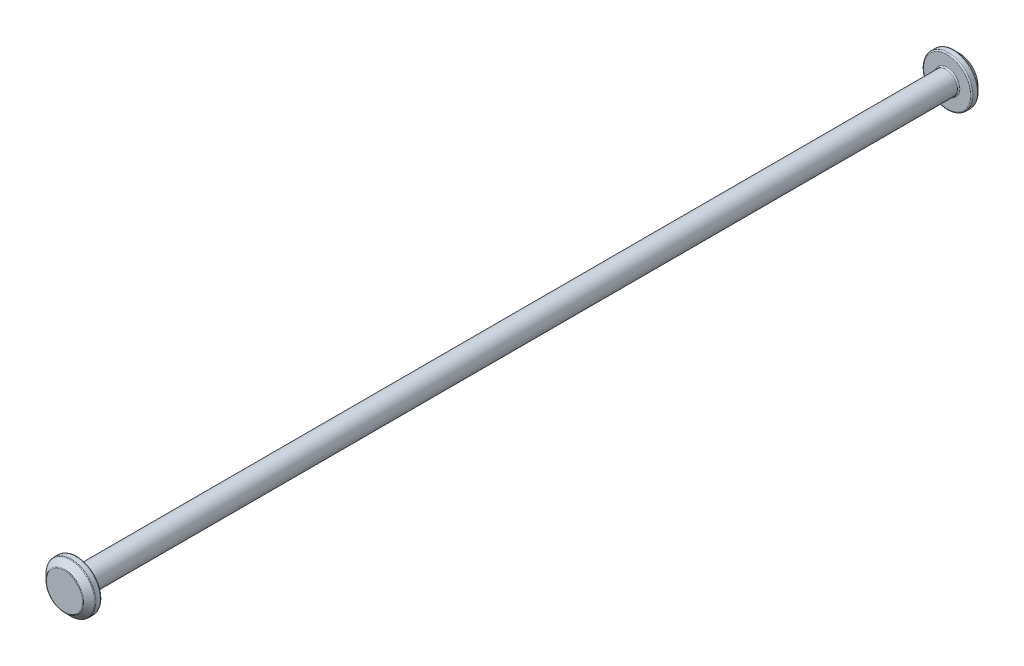
from build123d import *

# Parameters (mm, degrees)
SKETCH1_R           = 0.925
BOSS_EXTRUDE1_DEPTH = 35.25
SKETCH2_R           = 2
BOSS_EXTRUDE2_DEPTH = 1
CHAMFER1_SIZE       = 0.5
FILLET1_R           = 0.1


with BuildPart() as part:
    # Sketch1 → Boss-Extrude1 (new body)
    with BuildSketch(Plane.XY):
        Circle(SKETCH1_R)
    extrude(amount=BOSS_EXTRUDE1_DEPTH)

    # Sketch2 → Boss-Extrude2 (add)
    with BuildSketch(Plane.XY.offset(35.25)):
        Circle(SKETCH2_R)
    extrude(amount=BOSS_EXTRUDE2_DEPTH)

    # Chamfer1
    chamfer1_edges = [part.edges().sort_by_distance(p)[0] for p in [
        (-2, 0, 36.25),
    ]]
    chamfer(chamfer1_edges, length=CHAMFER1_SIZE)

    # Mirror1: part across plane


with BuildPart() as part_1:
    add(part.part)
    add(part.part.mirror(Plane.XY))

    # Fillet1
    fillet1_edges = [part_1.edges().sort_by_distance(p)[0] for p in [
        (-2, 0, 35.75),
        (-0.925, 0, -35.25),
        (-2, 0, -35.25),
        (-2, 0, -35.75),
        (-1.5, 0, -36.25),
        (-0.925, 0, 35.25),
        (-2, 0, 35.25),
        (-1.5, 0, 36.25),
    ]]
    fillet(fillet1_edges, radius=FILLET1_R)


solid = part_1.part
